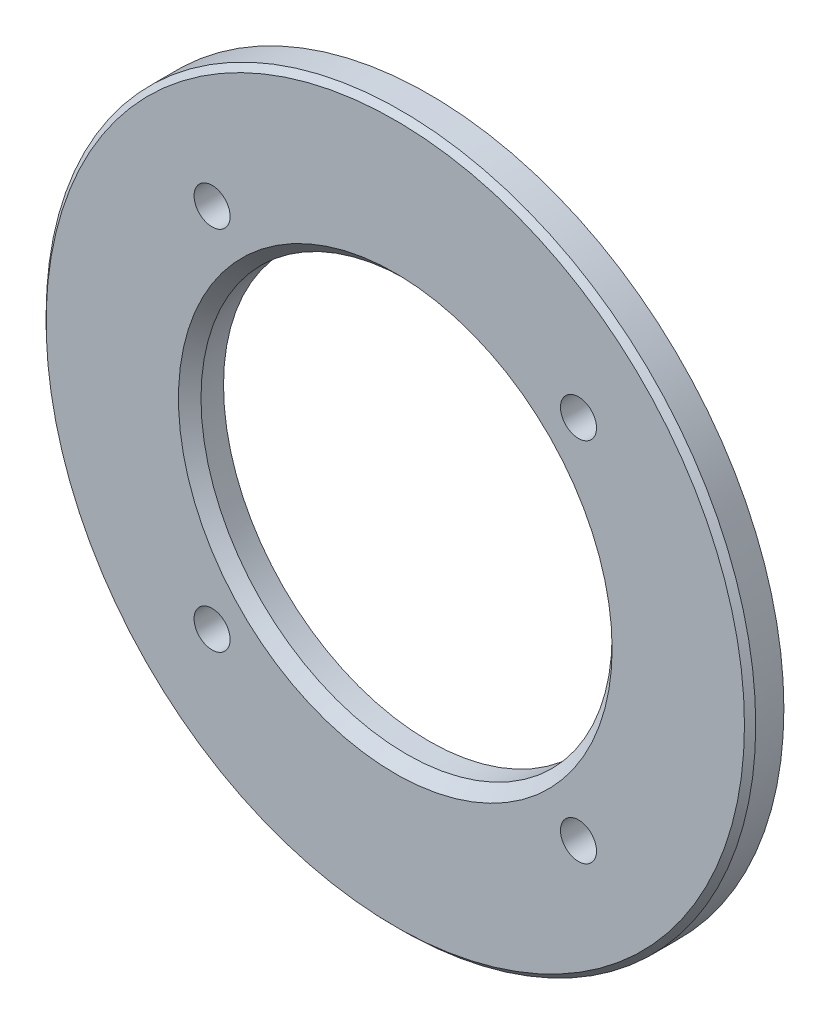
from build123d import *

# Parameters (mm, degrees)
SKETCH_1_R               = 31.5
SKETCH_1_R_2             = 18.25
EXTRUDE_1_DEPTH          = 3
CHAMFER_2_SIZE           = 1
CHAMFER_3_SIZE           = 0.5
SKETCH_2_R               = 1.6
CUT_EXTRUDE_1_DEPTH      = 45.648628198
PATTERN_CIRCULAR_1_COUNT = 4


with BuildPart() as part:
    # Эскиз1 → Бобышка-Вытянуть1 (new body)
    with BuildSketch(Plane.XY):
        Circle(SKETCH_1_R)
        Circle(SKETCH_1_R_2, mode=Mode.SUBTRACT)
    extrude(amount=EXTRUDE_1_DEPTH)

    # Фаска2
    chamfer_2_edges = [part.edges().sort_by_distance(p)[0] for p in [
        (-18.25, 0, 3),
    ]]
    chamfer(chamfer_2_edges, length=CHAMFER_2_SIZE)

    # Фаска3
    chamfer_3_edges = [part.edges().sort_by_distance(p)[0] for p in [
        (-31.5, 0, 3),
    ]]
    chamfer(chamfer_3_edges, length=CHAMFER_3_SIZE)

    # Эскиз2 → Вырез-Вытянуть1 (cut, through all)
    with BuildSketch(Plane(origin=(0, 0, 0), x_dir=(-1, 0, 0), z_dir=(0, 0, -1))):
        with Locations((-16.263455967, 16.263455967)):
            Circle(SKETCH_2_R)
    cut_extrude_1 = extrude(amount=-CUT_EXTRUDE_1_DEPTH, mode=Mode.SUBTRACT)

    # Круговой массив1: Вырез-Вытянуть1 ×4 about axis
    pattern_circular_1_axis = Axis((0, 0, 2), (0, 0, -1))
    for i in range(1, PATTERN_CIRCULAR_1_COUNT):
        add(cut_extrude_1.rotate(pattern_circular_1_axis, i * 360 / PATTERN_CIRCULAR_1_COUNT), mode=Mode.SUBTRACT)


solid = part.part
